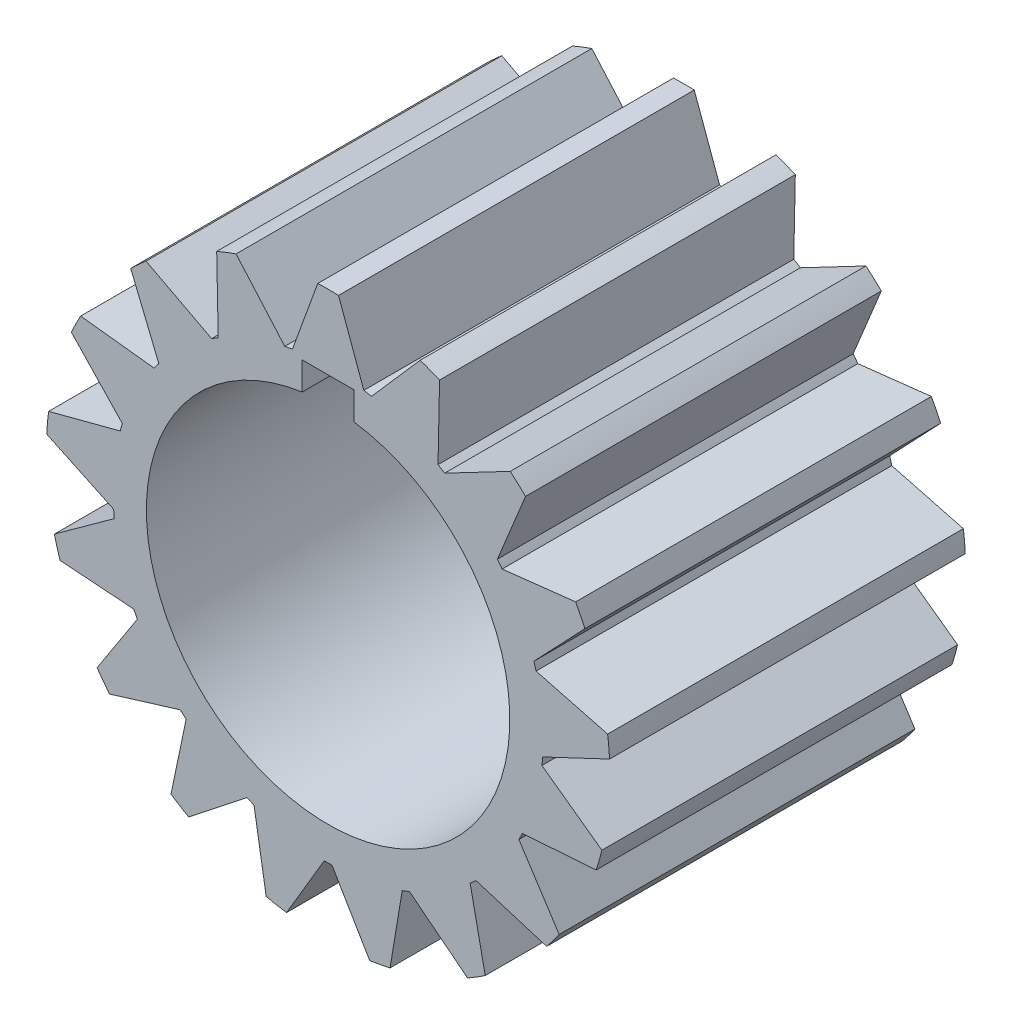
from build123d import *

# Parameters (mm, degrees)
BOSS_EXTRUDE1_DEPTH = 43.5102
CUT_EXTRUDE1_DEPTH  = 43.5102


with BuildPart() as part:
    # Sketch2 → Boss-Extrude1 (new body)
    with BuildSketch(Plane.XY):
        with BuildLine():
            Line((-4.366026501, 25.941944541), (-1.27, 34.448207442))
            ThreePointArc((-1.27, 34.448207442), (0, 34.47161), (1.27, 34.448207442))
            Line((1.27, 34.448207442), (4.366026501, 25.941944541))
            ThreePointArc((4.366026501, 25.941944541), (4.83385814, 25.858857079), (5.300112805, 25.767333549))
            Line((5.300112805, 25.767333549), (11.259888122, 32.580773709))
            ThreePointArc((11.259888122, 32.580773709), (12.452581833, 32.143819028), (13.628367585, 31.663219877))
            Line((13.628367585, 31.663219877), (13.442509735, 22.612952173))
            ThreePointArc((13.442509735, 22.612952173), (13.848735094, 22.366475142), (14.250442508, 22.11270138))
            Line((14.250442508, 22.11270138), (22.26906596, 26.31312595))
            ThreePointArc((22.26906596, 26.31312595), (23.223373486, 25.474827181), (24.14614861, 24.601939015))
            Line((24.14614861, 24.601939015), (20.703507542, 16.229955312))
            ThreePointArc((20.703507542, 16.229955312), (20.993263634, 15.8533768), (21.276170986, 15.471626358))
            Line((21.276170986, 15.471626358), (30.270683044, 16.491744725))
            ThreePointArc((30.270683044, 16.491744725), (30.857719866, 15.365318762), (31.402858467, 14.218029965))
            Line((31.402858467, 14.218029965), (25.168381933, 7.655013053))
            ThreePointArc((25.168381933, 7.655013053), (25.302535593, 7.199192074), (25.428434676, 6.741022466))
            Line((25.428434676, 6.741022466), (34.184076646, 4.443061991))
            ThreePointArc((34.184076646, 4.443061991), (34.324560189, 3.180638903), (34.418438279, 1.913897183))
            Line((34.418438279, 1.913897183), (26.234126882, -1.953781138))
            ThreePointArc((26.234126882, -1.953781138), (26.194559914, -2.427283433), (26.14644736, -2.899993864))
            Line((26.14644736, -2.899993864), (33.480721277, -8.205680884))
            ThreePointArc((33.480721277, -8.205680884), (33.155678459, -9.433603865), (32.785617282, -10.648718018))
            Line((32.785617282, -10.648718018), (23.756807626, -11.298706359))
            ThreePointArc((23.756807626, -11.298706359), (23.54886377, -11.725940863), (23.333237446, -12.149349953))
            Line((23.333237446, -12.149349953), (28.255608976, -19.746201087))
            ThreePointArc((28.255608976, -19.746201087), (27.508938632, -20.773786158), (26.724917, -21.773164845))
            Line((26.724917, -21.773164845), (18.07099986, -19.117678678))
            ThreePointArc((18.07099986, -19.117678678), (17.722763084, -19.440945003), (17.36874452, -19.757869009))
            Line((17.36874452, -19.757869009), (19.214420114, -28.619887416))
            ThreePointArc((19.214420114, -28.619887416), (18.14696421, -29.308353518), (17.054868589, -29.95702511))
            Line((17.054868589, -29.95702511), (9.944603428, -24.354702557))
            ThreePointArc((9.944603428, -24.354702557), (9.503105039, -24.530341795), (9.058506404, -24.697978373))
            Line((9.058506404, -24.697978373), (7.578217344, -33.628299361))
            ThreePointArc((7.578217344, -33.628299361), (6.334141716, -33.884665333), (5.081465671, -34.095023136))
            Line((5.081465671, -34.095023136), (0.475133198, -26.302488901))
            ThreePointArc((0.475133198, -26.302488901), (0, -26.30678), (-0.475133198, -26.302488901))
            Line((-0.475133198, -26.302488901), (-5.081465671, -34.095023136))
            ThreePointArc((-5.081465671, -34.095023136), (-6.334141716, -33.884665333), (-7.578217344, -33.628299361))
            Line((-7.578217344, -33.628299361), (-9.058506404, -24.697978373))
            ThreePointArc((-9.058506404, -24.697978373), (-9.503105039, -24.530341795), (-9.944603428, -24.354702557))
            Line((-9.944603428, -24.354702557), (-17.054868589, -29.95702511))
            ThreePointArc((-17.054868589, -29.95702511), (-18.14696421, -29.308353518), (-19.214420114, -28.619887416))
            Line((-19.214420114, -28.619887416), (-17.36874452, -19.757869009))
            ThreePointArc((-17.36874452, -19.757869009), (-17.722763084, -19.440945003), (-18.07099986, -19.117678678))
            Line((-18.07099986, -19.117678678), (-26.724917, -21.773164845))
            ThreePointArc((-26.724917, -21.773164845), (-27.508938632, -20.773786158), (-28.255608976, -19.746201087))
            Line((-28.255608976, -19.746201087), (-23.333237446, -12.149349953))
            ThreePointArc((-23.333237446, -12.149349953), (-23.54886377, -11.725940863), (-23.756807626, -11.298706359))
            Line((-23.756807626, -11.298706359), (-32.785617282, -10.648718018))
            ThreePointArc((-32.785617282, -10.648718018), (-33.155678459, -9.433603865), (-33.480721277, -8.205680884))
            Line((-33.480721277, -8.205680884), (-26.14644736, -2.899993864))
            ThreePointArc((-26.14644736, -2.899993864), (-26.194559914, -2.427283433), (-26.234126882, -1.953781138))
            Line((-26.234126882, -1.953781138), (-34.418438279, 1.913897183))
            ThreePointArc((-34.418438279, 1.913897183), (-34.324560189, 3.180638903), (-34.184076646, 4.443061991))
            Line((-34.184076646, 4.443061991), (-25.428434676, 6.741022466))
            ThreePointArc((-25.428434676, 6.741022466), (-25.302535593, 7.199192074), (-25.168381933, 7.655013053))
            Line((-25.168381933, 7.655013053), (-31.402858467, 14.218029965))
            ThreePointArc((-31.402858467, 14.218029965), (-30.857719866, 15.365318762), (-30.270683044, 16.491744725))
            Line((-30.270683044, 16.491744725), (-21.276170986, 15.471626358))
            ThreePointArc((-21.276170986, 15.471626358), (-20.993263634, 15.8533768), (-20.703507542, 16.229955312))
            Line((-20.703507542, 16.229955312), (-24.14614861, 24.601939015))
            ThreePointArc((-24.14614861, 24.601939015), (-23.223373486, 25.474827181), (-22.26906596, 26.31312595))
            Line((-22.26906596, 26.31312595), (-14.250442508, 22.11270138))
            ThreePointArc((-14.250442508, 22.11270138), (-13.848735094, 22.366475142), (-13.442509735, 22.612952173))
            Line((-13.442509735, 22.612952173), (-13.628367585, 31.663219877))
            ThreePointArc((-13.628367585, 31.663219877), (-12.452581833, 32.143819028), (-11.259888122, 32.580773709))
            Line((-11.259888122, 32.580773709), (-5.300112805, 25.767333549))
            ThreePointArc((-5.300112805, 25.767333549), (-4.83385814, 25.858857079), (-4.366026501, 25.941944541))
        make_face()
    extrude(amount=BOSS_EXTRUDE1_DEPTH)

    # Sketch4 → Cut-Extrude1 (cut)
    with BuildSketch(Plane.XY.offset(43.5102)):
        with BuildLine():
            Line((-3.175, 25.4), (3.175, 25.4))
            Line((3.175, 25.4), (3.175, 21.997045256))
            ThreePointArc((3.175, 21.997045256), (0, -22.225), (-3.175, 21.997045256))
            Line((-3.175, 21.997045256), (-3.175, 25.4))
        make_face()
    extrude(amount=-CUT_EXTRUDE1_DEPTH, mode=Mode.SUBTRACT)


solid = part.part
